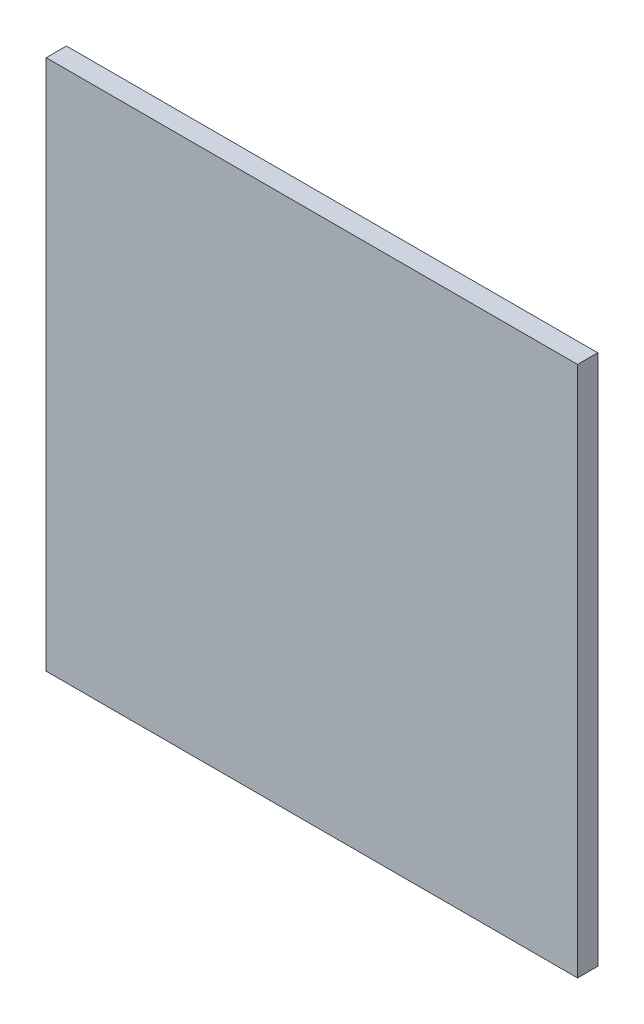
from build123d import *

# Parameters (mm, degrees)
SKETCH1_W           = 105
SKETCH1_H           = 105
BOSS_EXTRUDE1_DEPTH = 4
SKETCH2_R           = 3
CUT_EXTRUDE1_DEPTH  = 2
BOSS_EXTRUDE5_DEPTH = 12
SKETCH4_R           = 1.998701955
CUT_EXTRUDE2_DEPTH  = 12
FILLET1_R           = 1


with BuildPart() as part:
    # Sketch1 → Boss-Extrude1 (new body)
    with BuildSketch(Plane.XY):
        with Locations((52.5, 52.5)):
            Rectangle(SKETCH1_W, SKETCH1_H)
    extrude(amount=BOSS_EXTRUDE1_DEPTH)

    # Sketch2 → Cut-Extrude1 (cut)
    with BuildSketch(Plane(origin=(0, 0, 0), x_dir=(-1, 0, 0), z_dir=(0, 0, -1))):
        with Locations((-52.5, 52.5)):
            Circle(SKETCH2_R)
    extrude(amount=-CUT_EXTRUDE1_DEPTH, mode=Mode.SUBTRACT)

    # Sketch3 → Boss-Extrude5 (add)
    with BuildSketch(Plane(origin=(0, 0, 0), x_dir=(-1, 0, 0), z_dir=(0, 0, -1))):
        with BuildLine():
            Line((-46.5, 55), (-40, 55))
            Line((-40, 55), (-40, 53))
            Line((-40, 53), (-49.440588292, 53))
            ThreePointArc((-49.440588292, 53), (-55.6, 52.5), (-49.440588292, 52))
            Line((-49.440588292, 52), (-40, 52))
            Line((-40, 52), (-40, 50))
            Line((-40, 50), (-46.5, 50))
            ThreePointArc((-46.5, 50), (-59, 52.5), (-46.5, 55))
        make_face()
    extrude(amount=BOSS_EXTRUDE5_DEPTH)

    # Sketch4 → Cut-Extrude2 (cut)
    with BuildSketch(Plane(origin=(0, 55, 0), x_dir=(1, 0, 0), z_dir=(0, 1, 0))):
        with Locations((43.25, 6)):
            Circle(SKETCH4_R)
    extrude(amount=-CUT_EXTRUDE2_DEPTH, mode=Mode.SUBTRACT)

    # Fillet1
    fillet1_edges = [part.edges().sort_by_distance(p)[0] for p in [
        (40, 54, -12),
        (40, 51, -12),
    ]]
    fillet(fillet1_edges, radius=FILLET1_R)


solid = part.part
